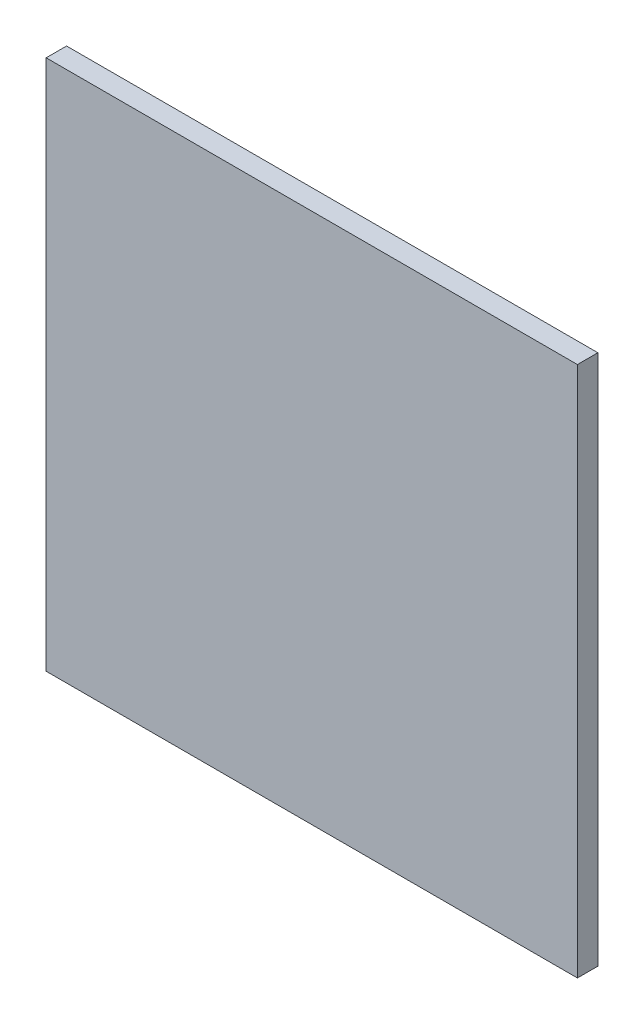
from build123d import *

# Parameters (mm, degrees)
SCHIZZO3_W                   = 130
SCHIZZO3_H                   = 130
ESTRUSIONE_ESTRUSIONE2_DEPTH = 5


with BuildPart() as part:
    # Schizzo3 → Estrusione-Estrusione2 (new body)
    with BuildSketch(Plane.XY):
        Rectangle(SCHIZZO3_W, SCHIZZO3_H)
    extrude(amount=ESTRUSIONE_ESTRUSIONE2_DEPTH)


solid = part.part
